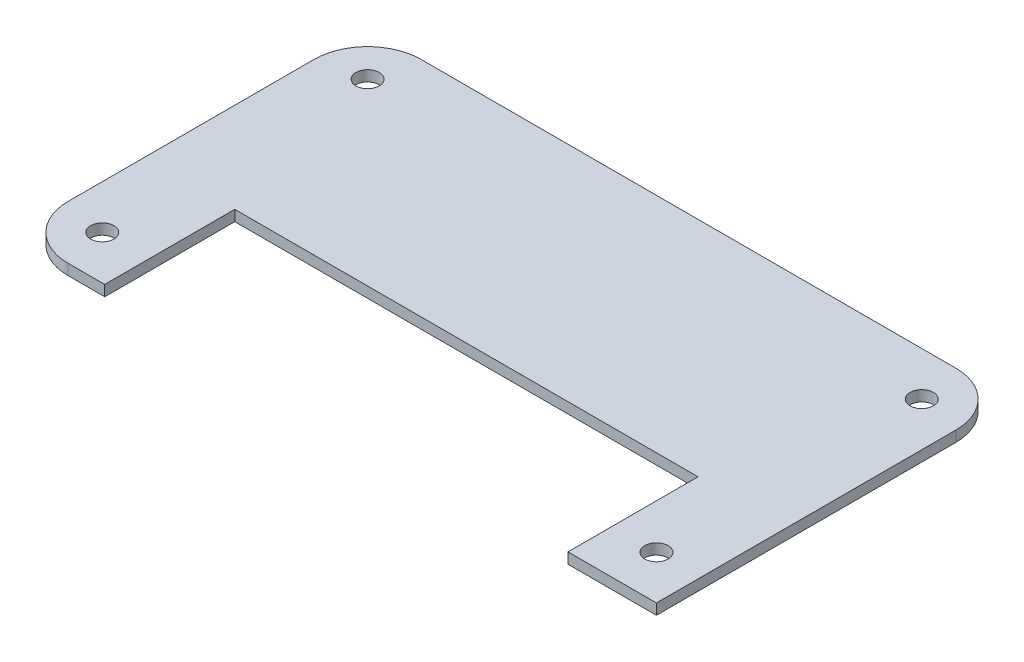
from build123d import *

# Parameters (mm, degrees)
CROQUIS1_R              = 2.175
SALIENTE_EXTRUIR1_DEPTH = 2


with BuildPart() as part:
    # Croquis1 → Saliente-Extruir1 (new body)
    with BuildSketch(Plane(origin=(0, 0, 0), x_dir=(1, 0, 0), z_dir=(0, 1, 0))):
        with BuildLine():
            Line((0, 0), (0, 56))
            ThreePointArc((0, 56), (-2.928932188, 63.071067812), (-10, 66))
            Line((-10, 66), (-110, 66))
            ThreePointArc((-110, 66), (-117.071067812, 63.071067812), (-120, 56))
            Line((-120, 56), (-120, 10))
            ThreePointArc((-120, 10), (-117.071067812, 2.928932188), (-110, 0))
            Line((-110, 0), (-103.13836414, 0))
            Line((-103.13836414, 0), (-103.13836414, 24.315705481))
            Line((-103.13836414, 24.315705481), (-16.541911164, 24.315705481))
            Line((-16.541911164, 24.315705481), (-16.541911164, 0))
            Line((-16.541911164, 0), (0, 0))
        make_face()
        with Locations((-8.2, 8.2)):
            Circle(CROQUIS1_R, mode=Mode.SUBTRACT)
        with Locations((-8.2, 57.8)):
            Circle(CROQUIS1_R, mode=Mode.SUBTRACT)
        with Locations((-111.8, 57.8)):
            Circle(CROQUIS1_R, mode=Mode.SUBTRACT)
        with Locations((-111.8, 8.2)):
            Circle(CROQUIS1_R, mode=Mode.SUBTRACT)
    extrude(amount=SALIENTE_EXTRUIR1_DEPTH)


solid = part.part
